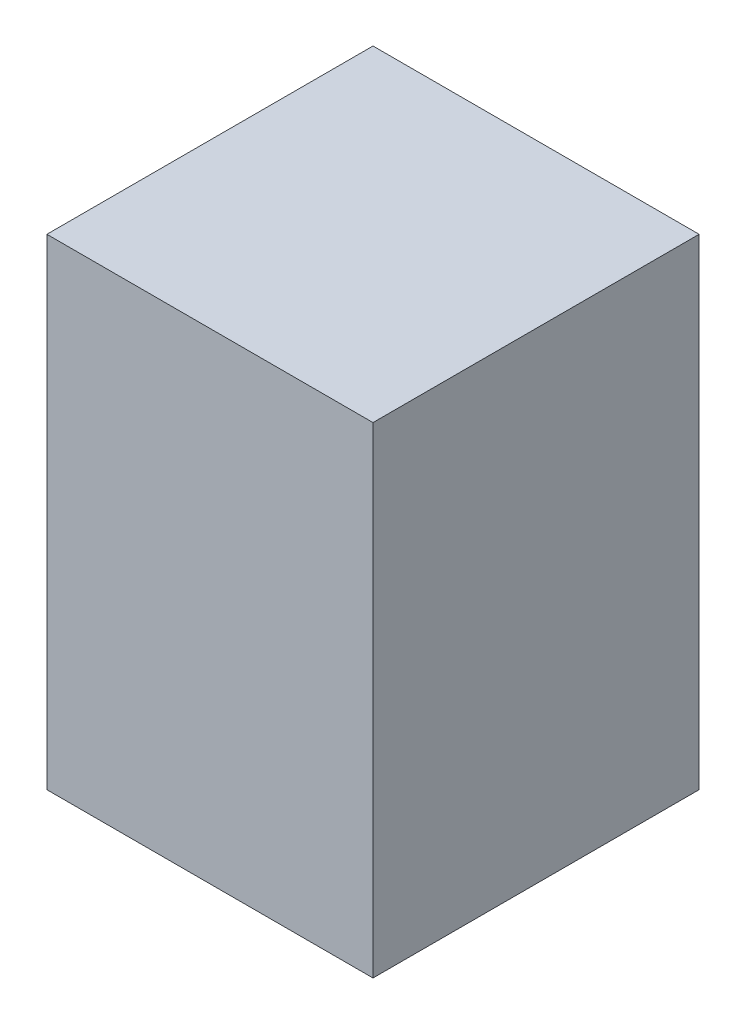
from build123d import *

# Parameters (mm, degrees)
SKETCH1_W           = 50.8
SKETCH1_H           = 50.8
BOSS_EXTRUDE1_DEPTH = 74.93


with BuildPart() as part:
    # Sketch1 → Boss-Extrude1 (new body)
    with BuildSketch(Plane(origin=(0, 0, 0), x_dir=(1, 0, 0), z_dir=(0, 1, 0))):
        with Locations((25.4, 25.4)):
            Rectangle(SKETCH1_W, SKETCH1_H)
    extrude(amount=BOSS_EXTRUDE1_DEPTH)


solid = part.part
